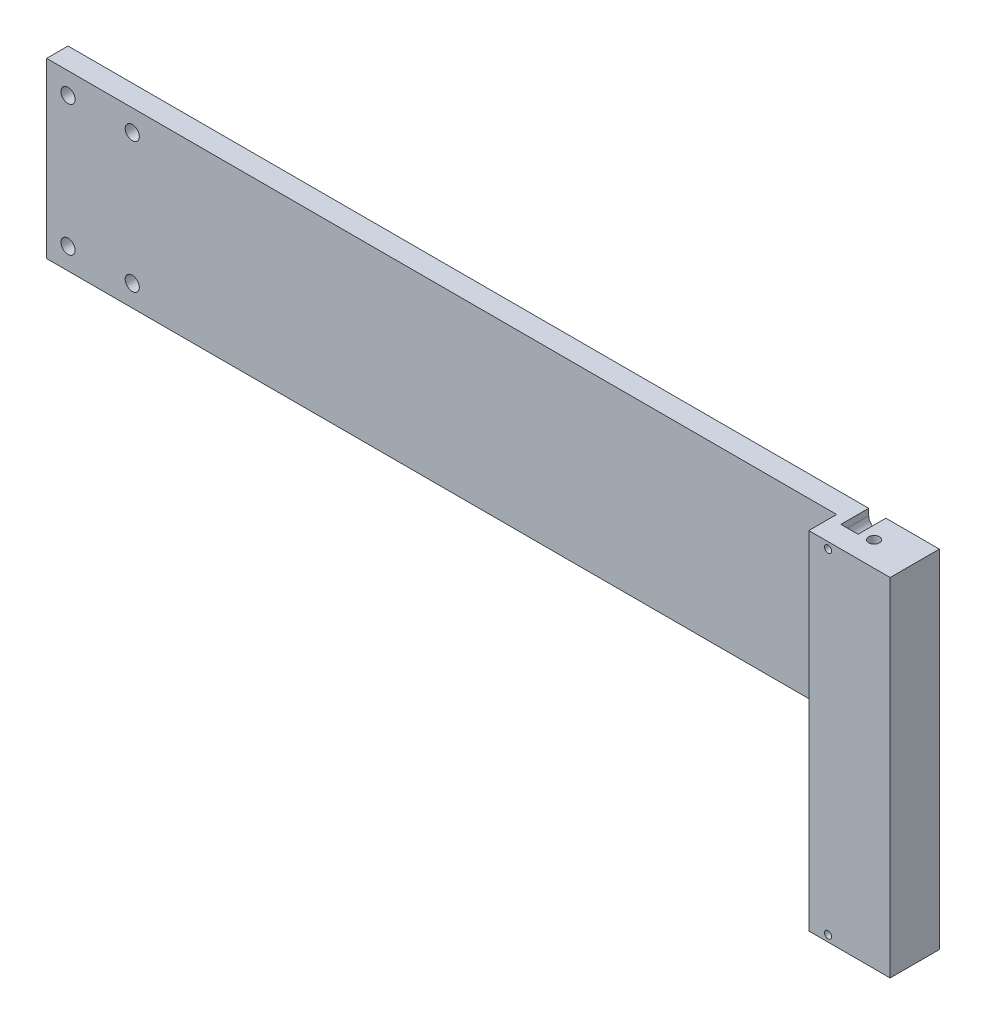
from build123d import *

# Parameters (mm, degrees)
SKETCH1_W           = 369
SKETCH1_H           = 81
BOSS_EXTRUDE1_DEPTH = 10
SKETCH2_W           = 23
SKETCH2_H           = 162
BOSS_EXTRUDE2_DEPTH = 38
SKETCH3_R           = 3.3
CUT_EXTRUDE1_DEPTH  = 13
SKETCH4_R           = 2.5
CUT_EXTRUDE2_DEPTH  = 163
SKETCH5_R           = 1.65
CUT_EXTRUDE3_DEPTH  = 24
CUT_EXTRUDE4_DEPTH  = 13


with BuildPart() as part:
    # Sketch1 → Boss-Extrude1 (new body)
    with BuildSketch(Plane.XY):
        with Locations((184.5, 40.5)):
            Rectangle(SKETCH1_W, SKETCH1_H)
    extrude(amount=BOSS_EXTRUDE1_DEPTH)

    # Sketch2 → Boss-Extrude2 (add)
    with BuildSketch(Plane(origin=(369, 0, 0), x_dir=(0, 0, -1), z_dir=(1, 0, 0))):
        with Locations((-11.5, 0)):
            Rectangle(SKETCH2_W, SKETCH2_H)
    extrude(amount=BOSS_EXTRUDE2_DEPTH)

    # Sketch3 → Cut-Extrude1 (cut)
    with BuildSketch(Plane(origin=(0, 0, 0), x_dir=(-1, 0, 0), z_dir=(0, 0, -1))):
        with Locations((-10, 71)):
            Circle(SKETCH3_R)
        with Locations((-10, 10)):
            Circle(SKETCH3_R)
        with Locations((-40, 10)):
            Circle(SKETCH3_R)
        with Locations((-40, 71)):
            Circle(SKETCH3_R)
    extrude(amount=-CUT_EXTRUDE1_DEPTH, mode=Mode.SUBTRACT)

    # Sketch4 → Cut-Extrude2 (cut, through all)
    with BuildSketch(Plane(origin=(0, 81, 0), x_dir=(1, 0, 0), z_dir=(0, 1, 0))):
        with Locations((388, -11.5)):
            Circle(SKETCH4_R)
    extrude(amount=-CUT_EXTRUDE2_DEPTH, mode=Mode.SUBTRACT)

    # Sketch5 → Cut-Extrude3 (cut, through all)
    with BuildSketch(Plane(origin=(0, 0, 0), x_dir=(-1, 0, 0), z_dir=(0, 0, -1))):
        with Locations((-378, -78)):
            Circle(SKETCH5_R)
        with Locations((-378, 78)):
            Circle(SKETCH5_R)
    extrude(amount=-CUT_EXTRUDE3_DEPTH, mode=Mode.SUBTRACT)

    # Sketch6 → Cut-Extrude4 (cut)
    with BuildSketch(Plane(origin=(0, 0, 0), x_dir=(-1, 0, 0), z_dir=(0, 0, -1))):
        with BuildLine():
            Line((-382, -78), (-382, -81))
            Line((-382, -81), (-374, -81))
            Line((-374, -81), (-374, -78))
            ThreePointArc((-374, -78), (-378, -74), (-382, -78))
        make_face()
        with BuildLine():
            Line((-374, 78), (-374, 81))
            Line((-374, 81), (-382, 81))
            Line((-382, 81), (-382, 78))
            ThreePointArc((-382, 78), (-378, 74), (-374, 78))
        make_face()
    extrude(amount=-CUT_EXTRUDE4_DEPTH, mode=Mode.SUBTRACT)


solid = part.part
